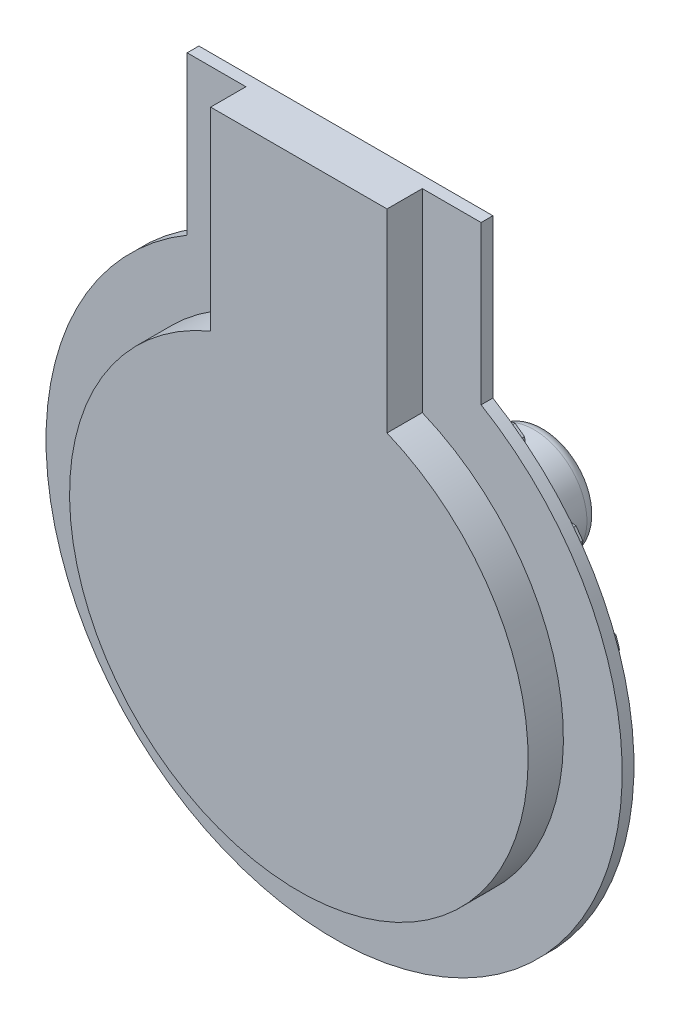
from build123d import *

# Parameters (mm, degrees)
Y_KSEKLIK_EKSTR_ZYON1_DEPTH = 30
Y_KSEKLIK_EKSTR_ZYON2_DEPTH = 10
IZIM5_R                     = 190
Y_KSEKLIK_EKSTR_ZYON3_DEPTH = 20
Y_KSEKLIK_EKSTR_ZYON4_DEPTH = 13
DAIRESEL_KAPLAMA1_COUNT     = 20
IZIM7_R                     = 45
Y_KSEKLIK_EKSTR_ZYON5_DEPTH = 150
RADYUS1_R                   = 10


with BuildPart() as part:
    # Çizim1 → Yükseklik-Ekstrüzyon1 (new body)
    with BuildSketch(Plane.XY):
        with BuildLine():
            Line((-2560, 390), (-2560, 225))
            ThreePointArc((-2560, 225), (-2635, -150), (-2710, 225))
            Line((-2710, 225), (-2710, 390))
            Line((-2710, 390), (-2560, 390))
        make_face()
    extrude(amount=-Y_KSEKLIK_EKSTR_ZYON1_DEPTH)

    # Çizim4 → Yükseklik-Ekstrüzyon2 (add)
    with BuildSketch(Plane(origin=(0, 0, -30), x_dir=(-1, 0, 0), z_dir=(0, 0, -1))):
        with BuildLine():
            Line((2510, 390), (2510, 255.713075057))
            ThreePointArc((2510, 255.713075057), (2635, -200), (2760, 255.713075057))
            Line((2760, 255.713075057), (2760, 390))
            Line((2760, 390), (2510, 390))
        make_face()
    extrude(amount=Y_KSEKLIK_EKSTR_ZYON2_DEPTH)

    # Çizim5 → Yükseklik-Ekstrüzyon3 (add)
    with BuildSketch(Plane(origin=(0, 0, -40), x_dir=(-1, 0, 0), z_dir=(0, 0, -1))):
        with Locations((2635, 45)):
            Circle(IZIM5_R)
    extrude(amount=Y_KSEKLIK_EKSTR_ZYON3_DEPTH)

    # Çizim6 → Yükseklik-Ekstrüzyon4 (add)
    with BuildSketch(Plane(origin=(0, 0, -40), x_dir=(-1, 0, 0), z_dir=(0, 0, -1))):
        Polygon((2639.970562748, 250.5), (2647, 257.529437252), (2647, 267.470562748), (2639.970562748, 274.5), (2630.029437252, 274.5), (2623, 267.470562748), (2623, 257.529437252), (2630.029437252, 250.5), align=None)
    y_kseklik_ekstr_zyon4 = extrude(amount=Y_KSEKLIK_EKSTR_ZYON4_DEPTH)

    # Dairesel Kaplama1: Yükseklik-Ekstrüzyon4 ×20 about axis
    dairesel_kaplama1_axis = Axis((-2635, 45, 0), (0, 0, 1))
    for i in range(1, DAIRESEL_KAPLAMA1_COUNT):
        add(y_kseklik_ekstr_zyon4.rotate(dairesel_kaplama1_axis, i * 360 / DAIRESEL_KAPLAMA1_COUNT))

    # Çizim7 → Yükseklik-Ekstrüzyon5 (add)
    with BuildSketch(Plane(origin=(0, 0, -60), x_dir=(-1, 0, 0), z_dir=(0, 0, -1))):
        with Locations((2635, 45)):
            Circle(IZIM7_R)
    extrude(amount=Y_KSEKLIK_EKSTR_ZYON5_DEPTH)

    # Radyus1
    radyus1_edges = [part.edges().sort_by_distance(p)[0] for p in [
        (-2590, 45, -60),
        (-2590, 45, -210),
    ]]
    fillet(radyus1_edges, radius=RADYUS1_R)


solid = part.part
